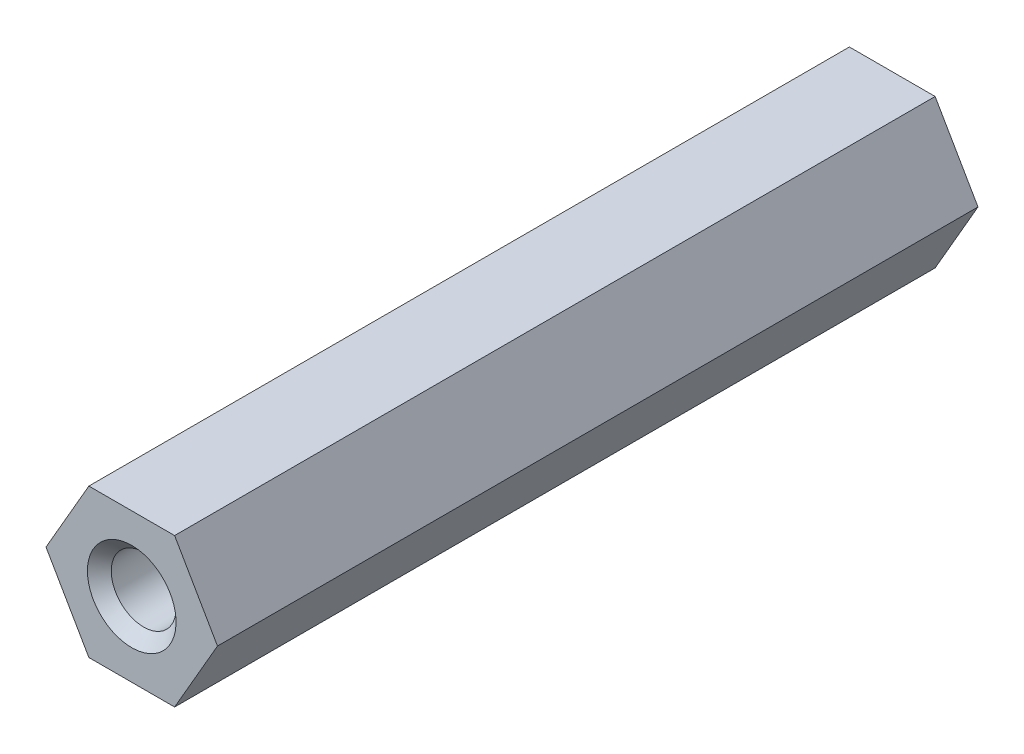
from build123d import *

# Parameters (mm, degrees)
BOSS_EXTRUDE1_DEPTH = 31.75


with BuildPart() as part:
    # Sketch1 → Boss-Extrude1 (new body)
    with BuildSketch(Plane.XY):
        Polygon((-3.579571669, 0), (-1.789785834, -3.1), (1.789785834, -3.1), (3.579571669, 0), (1.789785834, 3.1), (-1.789785834, 3.1), align=None)
    extrude(amount=BOSS_EXTRUDE1_DEPTH)

    # Sketch3 → 6-32 Tapped Hole1 (revolve, cut)
    with BuildSketch(Plane.YZ):
        Polygon((0, 0), (0, 31.75), (1.849999983, 31.75), (1.35255, 31.252550017), (1.35255, 0.497449983), (1.849999983, 0), align=None)
    revolve(axis=Axis((0, 0, -6.35), (0, 0, 1)), mode=Mode.SUBTRACT)


solid = part.part
